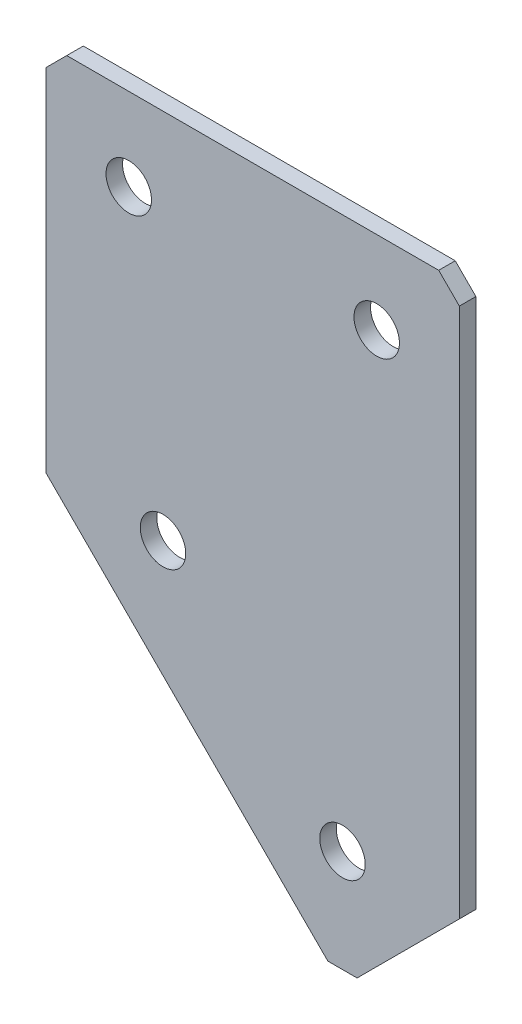
from build123d import *

# Parameters (mm, degrees)
EXTRUDE_1_DEPTH   = 2
HOLE_WIZARD_M51_D = 5.5
CHAMFER_1_SIZE    = 2.5


with BuildPart() as part:
    # Эскиз3 → Бобышка-Вытянуть1 (new body)
    with BuildSketch(Plane(origin=(0, 0, 0), x_dir=(1, 0, 0), z_dir=(0, 0, -1))):
        Polygon((0, 0), (50, 0), (50, 66.715728753), (35.857864376, 80.857864376), (0, 45), align=None)
    extrude(amount=EXTRUDE_1_DEPTH)

    # Отверстие с зазором M51 (through all)
    with Locations(Plane(origin=(0, 0, -2), x_dir=(1, 0, 0), z_dir=(0, 0, -1))):
        with Locations((10, 10), (40, 10), (14.142135624, 45), (35.857864376, 66.715728753)):
            Hole(HOLE_WIZARD_M51_D / 2)

    # Фаска1
    chamfer_1_edges = [part.edges().sort_by_distance(p)[0] for p in [
        (35.857864376, -80.857864376, -1),
        (50, 0, -1),
        (0, 0, -1),
    ]]
    chamfer(chamfer_1_edges, length=CHAMFER_1_SIZE)


solid = part.part
